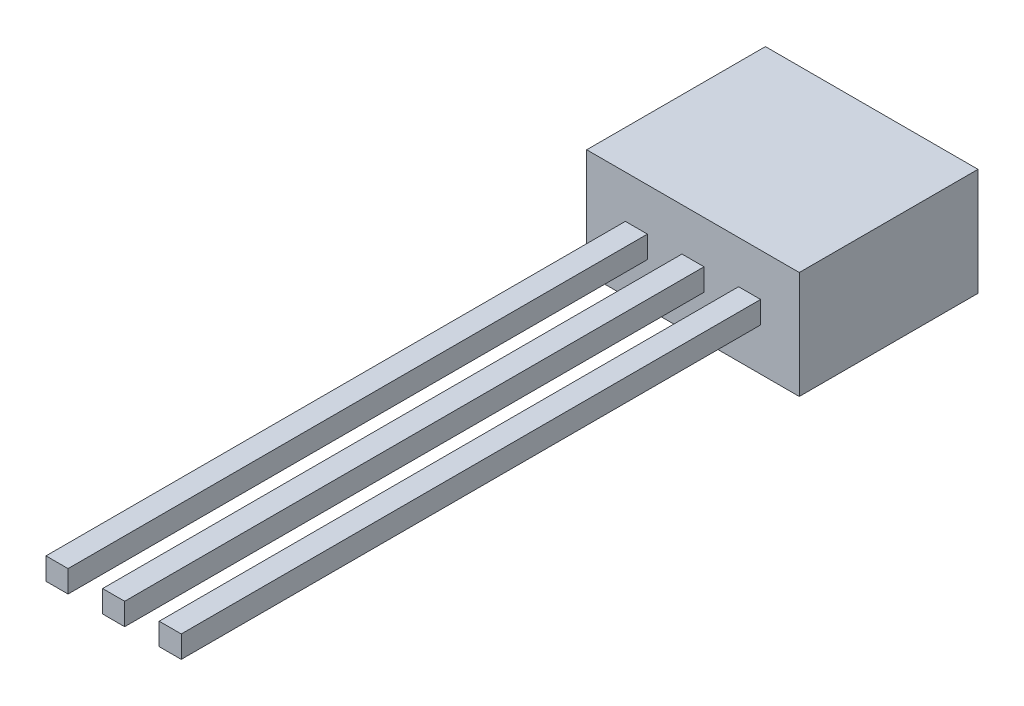
from build123d import *

# Parameters (mm, degrees)
SKETCH1_W           = 4.77
SKETCH1_H           = 4.01
BOSS_EXTRUDE1_DEPTH = 2.41
SKETCH3_W           = 0.495
SKETCH3_H           = 0.495
BOSS_EXTRUDE2_DEPTH = 13


with BuildPart() as part:
    # Sketch1 → Boss-Extrude1 (new body)
    with BuildSketch(Plane(origin=(0, 0, 0), x_dir=(1, 0, 0), z_dir=(0, 1, 0))):
        with Locations((2.385, -2.005)):
            Rectangle(SKETCH1_W, SKETCH1_H)
    extrude(amount=BOSS_EXTRUDE1_DEPTH)

    # Sketch3 → Boss-Extrude2 (add)
    with BuildSketch(Plane.XY.offset(4.01)):
        with Locations((3.655, 1.205)):
            Rectangle(SKETCH3_W, SKETCH3_H)
        with Locations((2.385, 1.205)):
            Rectangle(SKETCH3_W, SKETCH3_H)
        with Locations((1.115, 1.205)):
            Rectangle(SKETCH3_W, SKETCH3_H)
    extrude(amount=BOSS_EXTRUDE2_DEPTH)


solid = part.part
